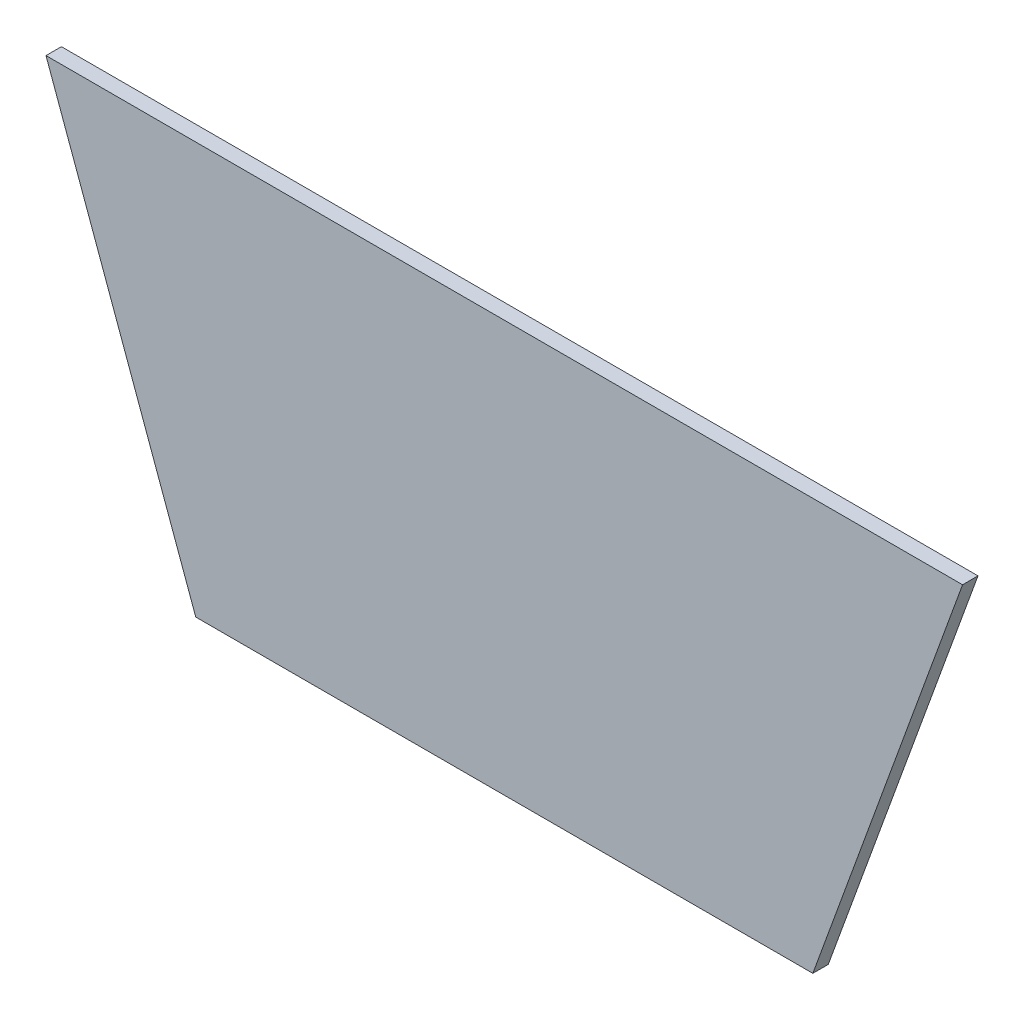
from build123d import *

# Parameters (mm, degrees)
BOSS_EXTRU_1_DEPTH = 3


with BuildPart() as part:
    # Esquisse1 → Boss.-Extru.1 (new body)
    with BuildSketch(Plane.XY):
        Polygon((-60, -9), (-89.117618741, 71), (89.117618741, 71), (60, -9), align=None)
    extrude(amount=BOSS_EXTRU_1_DEPTH)


solid = part.part
